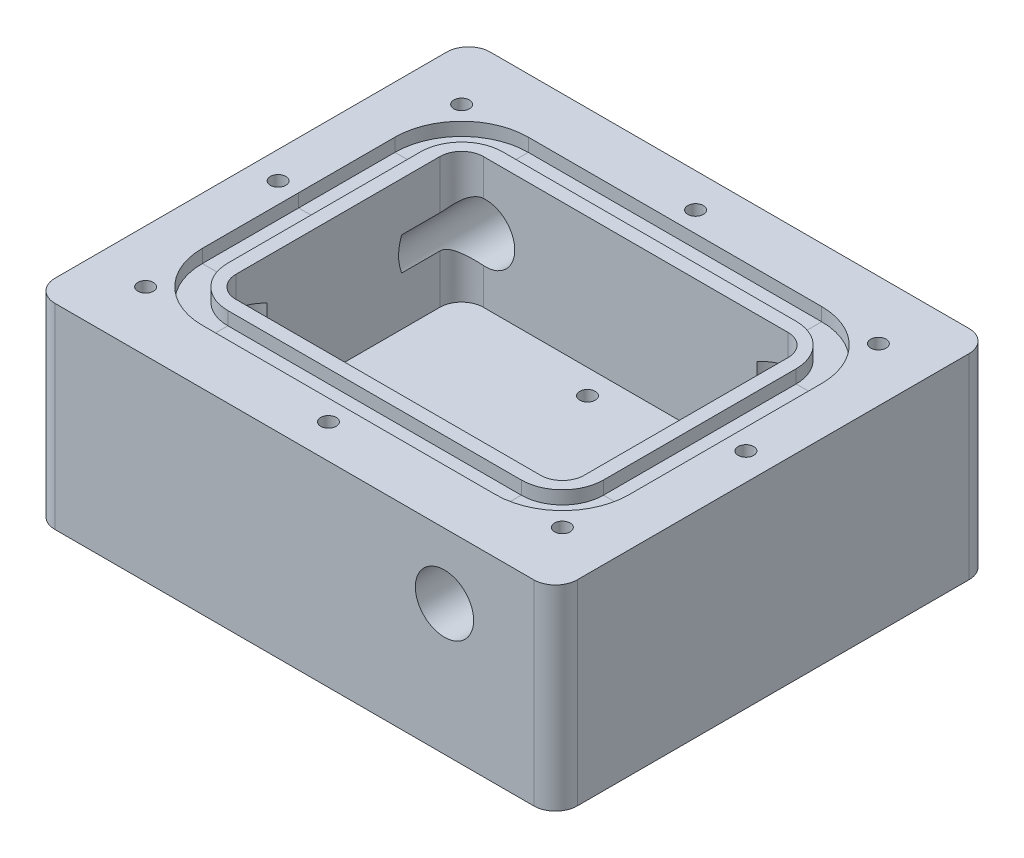
from build123d import *

# Parameters (mm, degrees)
SKETCH1_W                            = 76.2
SKETCH1_H                            = 63.5
BOSS_EXTRUDE1_DEPTH                  = 14.2875
SKETCH2_W                            = 50.8
SKETCH2_H                            = 36.1
CUT_EXTRUDE1_DEPTH                   = 15.875
CUT_EXTRUDE2_DEPTH                   = 3.175
FILLET1_R                            = 3.175
F_4_40_TAPPED_HOLE1_D                = 2.2606
F_4_40_TAPPED_HOLE1_DEPTH            = 3.320847242
F_4_40_TAPPED_HOLE1_TIP              = 0.679152758
F_1_4_NPT_TAPPED_HOLE1_AT_2_COUNT    = 2
F_1_4_NPT_TAPPED_HOLE1_AT_2_PITCH    = 53.729845058
M10X1_5_TAPPED_HOLE1_D               = 8.5
M10X1_5_TAPPED_HOLE1_DEPTH           = 22.446342369
M10X1_5_TAPPED_HOLE1_TIP             = 2.553657631
M10X1_5_TAPPED_HOLE1_ON_FACE_2_D     = 8.5
M10X1_5_TAPPED_HOLE1_ON_FACE_2_DEPTH = 22.446342369
M10X1_5_TAPPED_HOLE1_ON_FACE_2_TIP   = 2.553657631
SKETCH16_W                           = 3.724215622
SKETCH16_H                           = 1.92405
FILLET2_R                            = 3.175
F_4_40_TAPPED_HOLE2_D                = 2.2606
F_4_40_TAPPED_HOLE2_DEPTH            = 6.920847242
F_4_40_TAPPED_HOLE2_TIP              = 0.679152758


with BuildPart() as part:
    # Sketch1 → Boss-Extrude1 (new body, symmetric)
    with BuildSketch(Plane(origin=(0, 0, 0), x_dir=(1, 0, 0), z_dir=(0, 1, 0))):
        Rectangle(SKETCH1_W, SKETCH1_H)
    extrude(amount=BOSS_EXTRUDE1_DEPTH, both=True)

    # Sketch2 → Cut-Extrude1 (cut)
    with BuildSketch(Plane(origin=(0, 14.2875, 0), x_dir=(1, 0, 0), z_dir=(0, 1, 0))):
        Rectangle(SKETCH2_W, SKETCH2_H)
    extrude(amount=-CUT_EXTRUDE1_DEPTH, mode=Mode.SUBTRACT)

    # Sketch3 → Cut-Extrude2 (cut)
    with BuildSketch(Plane(origin=(0, -1.5875, 0), x_dir=(1, 0, 0), z_dir=(0, 1, 0))):
        Polygon((-25.4, -7.05), (-14.4, -7.05), (-14.4, -18.05), (25.4, -18.05), (25.4, 7.05), (14.4, 7.05), (14.4, 18.05), (-25.4, 18.05), align=None)
    extrude(amount=-CUT_EXTRUDE2_DEPTH, mode=Mode.SUBTRACT)

    # Fillet1
    fillet1_edges = [part.edges().sort_by_distance(p)[0] for p in [
        (25.4, 6.35, -18.05),
        (25.4, 4.7625, 18.05),
        (-25.4, 6.35, 18.05),
        (-25.4, 4.7625, -18.05),
        (-14.4, -3.175, 18.05),
        (-14.4, -3.175, 7.05),
        (-25.4, -3.175, 7.05),
        (14.4, -3.175, -18.05),
        (14.4, -3.175, -7.05),
        (25.4, -3.175, -7.05),
    ]]
    fillet(fillet1_edges, radius=FILLET1_R)

    # #4-40 Tapped Hole1
    with Locations(Plane(origin=(10.9465, -4.7625, -11.6905), x_dir=(0, 0, 1), z_dir=(0, 1, 0))):
        with Locations((0, 0), (26.16, -7.493), (-2.779, -14.4), (23.381, -21.893)):
            Hole(F_4_40_TAPPED_HOLE1_D / 2, depth=F_4_40_TAPPED_HOLE1_DEPTH)
            with Locations((0, 0, -(F_4_40_TAPPED_HOLE1_DEPTH + F_4_40_TAPPED_HOLE1_TIP / 2))):  # 118° drill point
                Cone(0, F_4_40_TAPPED_HOLE1_D / 2, F_4_40_TAPPED_HOLE1_TIP, mode=Mode.SUBTRACT)

    # Sketch9 → 1/4 NPT Tapped Hole1 (revolve, cut)
    with BuildSketch(Plane(origin=(-22.225, -14.2875, 14.875), x_dir=(0, 0, -1), z_dir=(1, 0, 0))):
        Polygon((0, 0), (0, 26), (5.5626, 22.657652721), (5.5626, 10.02), (5.943676082, 10.02), (6.2436883, 0), align=None)
    f_1_4_npt_tapped_hole1 = revolve(axis=Axis((-22.225, -20.6375, 14.875), (0, 1, 0)), mode=Mode.SUBTRACT)

    # 1/4 NPT Tapped Hole1 at 2: 1/4 NPT Tapped Hole1 ×2
    with Locations(*[Vector(0.830543992, 0, -0.55695303) * (i * F_1_4_NPT_TAPPED_HOLE1_AT_2_PITCH) for i in range(1, F_1_4_NPT_TAPPED_HOLE1_AT_2_COUNT)]):
        add(f_1_4_npt_tapped_hole1, mode=Mode.SUBTRACT)

    # M10x1.5 Tapped Hole1
    with Locations(Plane(origin=(-21.9, 4.7625, -31.75), x_dir=(-1, 0, 0), z_dir=(0, 0, -1))):
        with Locations((0, 0)):
            Hole(M10X1_5_TAPPED_HOLE1_D / 2, depth=M10X1_5_TAPPED_HOLE1_DEPTH)
            with Locations((0, 0, -(M10X1_5_TAPPED_HOLE1_DEPTH + M10X1_5_TAPPED_HOLE1_TIP / 2))):  # 118° drill point
                Cone(0, M10X1_5_TAPPED_HOLE1_D / 2, M10X1_5_TAPPED_HOLE1_TIP, mode=Mode.SUBTRACT)

    # M10x1.5 Tapped Hole1 on face 2
    with Locations(Plane(origin=(21.9, 4.7625, 31.75), x_dir=(1, 0, 0), z_dir=(0, 0, 1))):
        with Locations((0, 0)):
            Hole(M10X1_5_TAPPED_HOLE1_ON_FACE_2_D / 2, depth=M10X1_5_TAPPED_HOLE1_ON_FACE_2_DEPTH)
            with Locations((0, 0, -(M10X1_5_TAPPED_HOLE1_ON_FACE_2_DEPTH + M10X1_5_TAPPED_HOLE1_ON_FACE_2_TIP / 2))):  # 118° drill point
                Cone(0, M10X1_5_TAPPED_HOLE1_ON_FACE_2_D / 2, M10X1_5_TAPPED_HOLE1_ON_FACE_2_TIP, mode=Mode.SUBTRACT)

    # Cut-Sweep1: sweep along a path in Sketch14
    with BuildLine(Plane(origin=(0, 14.2875, 0), x_dir=(1, 0, 0), z_dir=(0, 1, 0))) as cut_sweep1_path:
        Line((-21.4, 20.05), (21.4, 20.05))
        ThreePointArc((21.4, 20.05), (25.642640687, 18.292640687), (27.4, 14.05))
        Line((27.4, 14.05), (27.4, -14.05))
        ThreePointArc((27.4, -14.05), (25.642640687, -18.292640687), (21.4, -20.05))
        Line((21.4, -20.05), (-21.4, -20.05))
        ThreePointArc((-21.4, -20.05), (-25.642640687, -18.292640687), (-27.4, -14.05))
        Line((-27.4, -14.05), (-27.4, 14.05))
        ThreePointArc((-27.4, 14.05), (-25.642640687, 18.292640687), (-21.4, 20.05))
    # Sketch16 → Cut-Sweep1 (sweep, cut)
    with BuildSketch(Plane.XY):
        with Locations((-29.262107811, 13.325475)):
            Rectangle(SKETCH16_W, SKETCH16_H)
    sweep(path=cut_sweep1_path.line, mode=Mode.SUBTRACT)

    # Fillet2
    fillet2_edges = [part.edges().sort_by_distance(p)[0] for p in [
        (38.1, 0, 31.75),
        (-38.1, 0, 31.75),
        (-38.1, 0, -31.75),
        (38.1, 0, -31.75),
    ]]
    fillet(fillet2_edges, radius=FILLET2_R)

    # #4-40 Tapped Hole2
    with Locations(Plane(origin=(0, 14.2875, 0), x_dir=(1, 0, 0), z_dir=(0, 1, 0))):
        with Locations((34.124215622, 0), (30.228658441, 23.222452534), (-30.397379151, 23.047379151), (30.397379151, -23.047379151), (-30.397379151, -23.047379151), (0, -26.774215622), (-34.124215622, 0), (0.004913792, 26.774215622)):
            Hole(F_4_40_TAPPED_HOLE2_D / 2, depth=F_4_40_TAPPED_HOLE2_DEPTH)
            with Locations((0, 0, -(F_4_40_TAPPED_HOLE2_DEPTH + F_4_40_TAPPED_HOLE2_TIP / 2))):  # 118° drill point
                Cone(0, F_4_40_TAPPED_HOLE2_D / 2, F_4_40_TAPPED_HOLE2_TIP, mode=Mode.SUBTRACT)


solid = part.part
